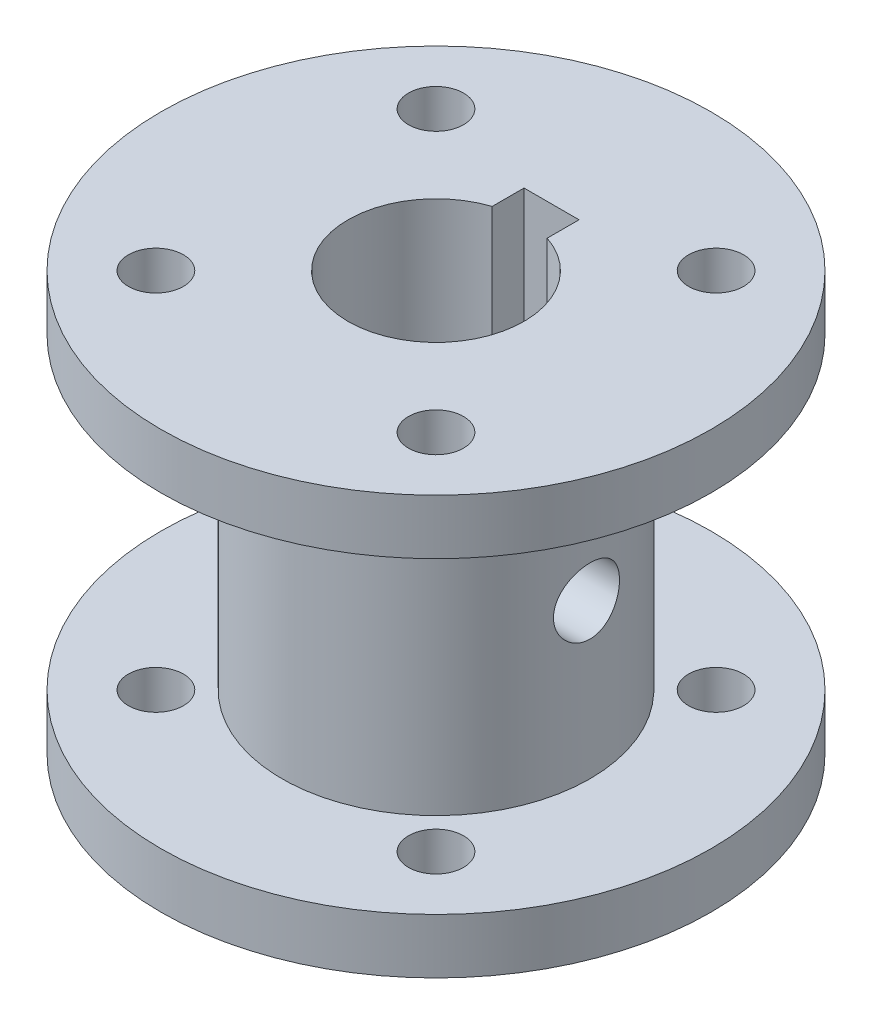
from build123d import *

# Parameters (mm, degrees)
SKETCH2_R               = 2.5
CUT_EXTRUDE1_DEPTH      = 39
SKETCH3_R               = 3
CUT_EXTRUDE2_DEPTH      = 26
CUT_EXTRUDE2_DEPTH_BACK = 26


with BuildPart() as part:
    # Sketch1 → Revolve1 (revolve)
    with BuildSketch(Plane.XY):
        Polygon((0, 30.794117647), (25, 30.794117647), (25, 25.794117647), (14, 25.794117647), (14, -2.205882353), (25, -2.205882353), (25, -7.205882353), (0, -7.205882353), align=None)
    revolve(axis=Axis((0, -19.166666667, 0), (0, 1, 0)))

    # Sketch2 → Cut-Extrude1 (cut, through all)
    with BuildSketch(Plane(origin=(0, 30.794117647, 0), x_dir=(1, 0, 0), z_dir=(0, 1, 0))):
        with Locations((12.727922061, 12.727922061)):
            Circle(SKETCH2_R)
        with Locations((12.727922061, -12.727922061)):
            Circle(SKETCH2_R)
        with Locations((-12.727922061, -12.727922061)):
            Circle(SKETCH2_R)
        with Locations((-12.727922061, 12.727922061)):
            Circle(SKETCH2_R)
        with BuildLine():
            Line((-2.5, 7.599342077), (-2.5, 10.5))
            Line((-2.5, 10.5), (2.5, 10.5))
            Line((2.5, 10.5), (2.5, 7.599342077))
            ThreePointArc((2.5, 7.599342077), (0, -8), (-2.5, 7.599342077))
        make_face()
    extrude(amount=-CUT_EXTRUDE1_DEPTH, mode=Mode.SUBTRACT)

    # Sketch3 → Cut-Extrude2 (cut, two sides)
    with BuildSketch(Plane(origin=(0, 0, 0), x_dir=(0, 0, -1), z_dir=(1, 0, 0))) as cut_extrude2_sk:
        with Locations((0, 11.794117647)):
            Circle(SKETCH3_R)
    extrude(amount=CUT_EXTRUDE2_DEPTH, mode=Mode.SUBTRACT)
    extrude(cut_extrude2_sk.sketch, amount=-CUT_EXTRUDE2_DEPTH_BACK, mode=Mode.SUBTRACT)


solid = part.part
